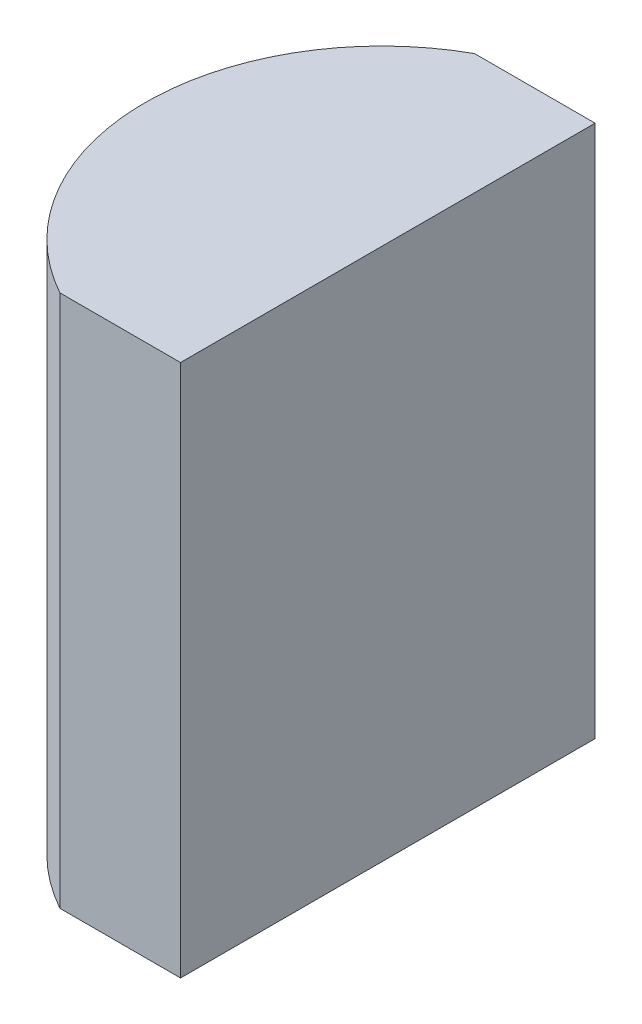
from build123d import *

# Parameters (mm, degrees)
EXTRUDE_1_DEPTH = 9


with BuildPart() as part:
    # 草图1 → 凸台-拉伸1 (new body)
    with BuildSketch(Plane(origin=(0, 0, 0), x_dir=(1, 0, 0), z_dir=(0, 1, 0))):
        with BuildLine():
            Line((2.418712662, 3.5), (4.455204335, 3.5))
            Line((4.455204335, 3.5), (4.455204335, -3.5))
            Line((4.455204335, -3.5), (2.418712662, -3.5))
            ThreePointArc((2.418712662, -3.5), (0.355204335, 0), (2.418712662, 3.5))
        make_face()
    extrude(amount=EXTRUDE_1_DEPTH)


solid = part.part
